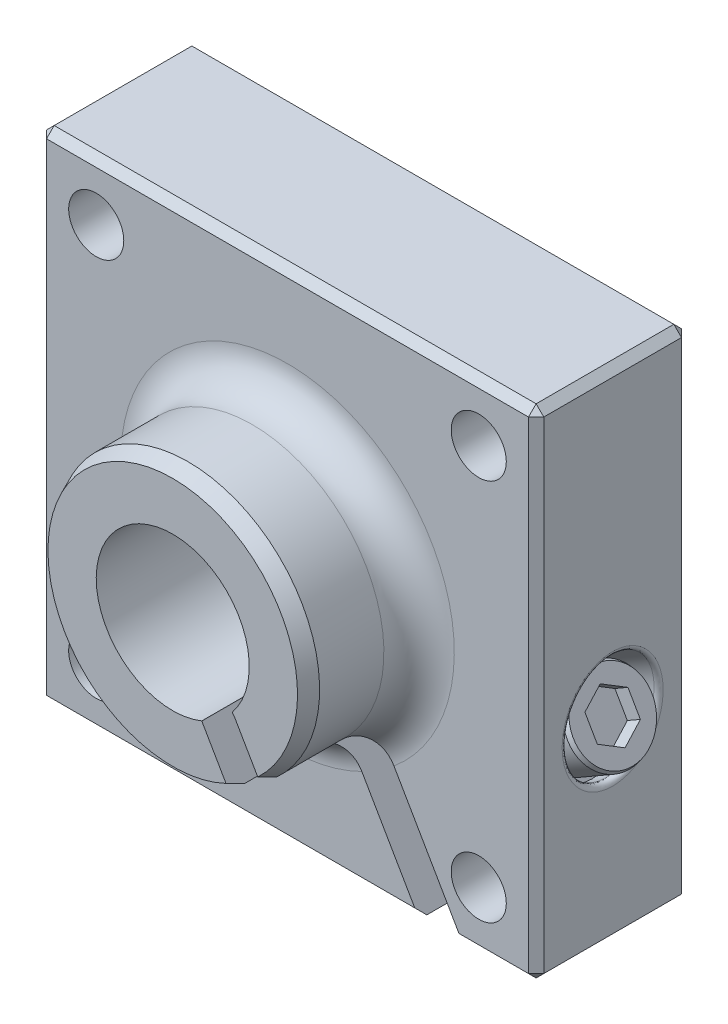
from build123d import *

# Parameters (mm, degrees)
SKETCH4_W               = 41.275
SKETCH4_H               = 41.275
SKETCH4_R               = 2.286
SKETCH4_R_2             = 6.35
BOSS_EXTRUDE1_DEPTH     = 12.7
SKETCH6_R               = 10.922
SKETCH6_R_2             = 6.35
BOSS_EXTRUDE2_DEPTH     = 9.525
CUT_EXTRUDE1_DEPTH      = 23.225
CHAMFER1_SIZE           = 1.27
CHAMFER1_SIZE2          = 0.56544043
CHAMFER3_SIZE           = 0.635
SKETCH18_R              = 2.1463
CUT_EXTRUDE2_DEPTH      = 18.847032
CUT_EXTRUDE2_DEPTH_BACK = 2.54
SKETCH19_R              = 3.81
CUT_EXTRUDE3_DEPTH      = 4.1656
CUT_EXTRUDE3_DEPTH_BACK = 13.484099492
CUT_EXTRUDE4_DEPTH      = 1.24968
CHAMFER4_SIZE           = 0.381
CHAMFER4_SIZE2          = 0.169632129
FILLET1_R               = 0.381
FILLET2_R               = 2.921


with BuildPart() as part:
    # Sketch4 → Boss-Extrude1 (new body)
    with BuildSketch(Plane.XY):
        Rectangle(SKETCH4_W, SKETCH4_H)
        with Locations((-15.875, -15.875)):
            Circle(SKETCH4_R, mode=Mode.SUBTRACT)
        with Locations((15.875, -15.875)):
            Circle(SKETCH4_R, mode=Mode.SUBTRACT)
        with Locations((15.875, 15.875)):
            Circle(SKETCH4_R, mode=Mode.SUBTRACT)
        with Locations((-15.875, 15.875)):
            Circle(SKETCH4_R, mode=Mode.SUBTRACT)
        Circle(SKETCH4_R_2, mode=Mode.SUBTRACT)
    extrude(amount=-BOSS_EXTRUDE1_DEPTH)

    # Sketch6 → Boss-Extrude2 (add)
    with BuildSketch(Plane.XY):
        Circle(SKETCH6_R)
        Circle(SKETCH6_R_2, mode=Mode.SUBTRACT)
    extrude(amount=BOSS_EXTRUDE2_DEPTH)

    # Sketch8 → Cut-Extrude1 (cut, through all)
    with BuildSketch(Plane.XY.offset(9.525)):
        with BuildLine():
            Line((11.388684671, -21.43125), (2.415183293, -5.88868969))
            ThreePointArc((2.415183293, -5.88868969), (2.996248621, -3.720124362), (5.16481395, -4.30118969))
            Line((5.16481395, -4.30118969), (14.138315329, -19.84375))
            ThreePointArc((14.138315329, -19.84375), (13.55725, -22.012315329), (11.388684671, -21.43125))
        make_face()
    extrude(amount=-CUT_EXTRUDE1_DEPTH, mode=Mode.SUBTRACT)

    # Chamfer1
    chamfer1_edges = [part.edges().sort_by_distance(p)[0] for p in [
        (-6.09154739, 9.065491404, 9.525),
    ]]
    chamfer1_side = [part.faces().sort_by_distance(p)[0] for p in [
        (-6.09154739, 9.065491404, 4.7625),
    ]]
    chamfer(chamfer1_edges, length=CHAMFER1_SIZE, length2=CHAMFER1_SIZE2, reference=chamfer1_side[0])

    # Chamfer3
    chamfer3_edges = [part.edges().sort_by_distance(p)[0] for p in [
        (0, 20.6375, -12.7),
        (-20.6375, 0, -12.7),
        (-4.853543552, -20.6375, -12.7),
        (-20.6375, 0, 0),
        (17.49425, -20.6375, -12.7),
        (0, 20.6375, 0),
        (17.49425, -20.6375, 0),
        (20.6375, 0, 0),
        (-4.853543552, -20.6375, 0),
        (20.6375, 0, -12.7),
        (-20.6375, -20.6375, -6.35),
        (-20.6375, 20.6375, -6.35),
        (20.6375, 20.6375, -6.35),
        (20.6375, -20.6375, -6.35),
    ]]
    chamfer(chamfer3_edges, length=CHAMFER3_SIZE)

    # Sketch18 → Cut-Extrude2 (cut, two sides)
    with BuildSketch(Plane(origin=(13.602877332, 7.853624889, 0), x_dir=(0, 0, -1), z_dir=(-0.866025404, -0.5, 0))) as cut_extrude2_sk:
        with Locations((6.35, 14.069245336)):
            Circle(SKETCH18_R)
    extrude(amount=CUT_EXTRUDE2_DEPTH, mode=Mode.SUBTRACT)
    extrude(cut_extrude2_sk.sketch, amount=-CUT_EXTRUDE2_DEPTH_BACK, mode=Mode.SUBTRACT)

    # Sketch19 → Cut-Extrude3 (cut, two sides)
    with BuildSketch(Plane(origin=(13.602877332, 7.853624889, 0), x_dir=(0, 0, -1), z_dir=(-0.866025404, -0.5, 0))) as cut_extrude3_sk:
        with Locations((6.35, 14.069245336)):
            Circle(SKETCH19_R)
    extrude(amount=CUT_EXTRUDE3_DEPTH, mode=Mode.SUBTRACT)
    extrude(cut_extrude3_sk.sketch, amount=-CUT_EXTRUDE3_DEPTH_BACK, mode=Mode.SUBTRACT)

    # Sketch21 → Revolve2 (revolve)
    with BuildSketch(Plane(origin=(7.034622668, -12.184323873, 0), x_dir=(-0.866025404, -0.5, 0), z_dir=(0.5, -0.866025404, 0))):
        Polygon((-15.707249779, 6.35), (7.878464507, 6.35), (7.878464507, 8.4328), (-11.922649779, 8.4328), (-11.922649779, 9.779), (-15.707249779, 9.779), align=None)
    revolve(axis=Axis((20.6375, -4.330698984, -6.35), (-0.866025404, -0.5, 0)))

    # Sketch22 → Cut-Extrude4 (cut)
    with BuildSketch(Plane(origin=(13.602877332, 7.853624889, 0), x_dir=(0, 0, -1), z_dir=(0.866025404, 0.5, 0))):
        Polygon((6.35, -16.131468329), (8.1359375, -15.100356833), (8.1359375, -13.03813384), (6.35, -12.007022344), (4.5640625, -13.03813384), (4.5640625, -15.100356833), align=None)
    extrude(amount=-CUT_EXTRUDE4_DEPTH, mode=Mode.SUBTRACT)

    # Chamfer4
    chamfer4_edges = [part.edges().sort_by_distance(p)[0] for p in [
        (20.6375, -4.330698984, -2.921),
    ]]
    chamfer4_side = [part.faces().sort_by_distance(p)[0] for p in [
        (18.998720128, -5.276848984, -2.921),
    ]]
    chamfer(chamfer4_edges, length=CHAMFER4_SIZE, length2=CHAMFER4_SIZE2, reference=chamfer4_side[0])

    # Fillet1
    fillet1_edges = [part.edges().sort_by_distance(p)[0] for p in [
        (20.6375, -8.730108035, -6.35000004),
        (20.6375, 0.068710067, -6.34999996),
    ]]
    fillet(fillet1_edges, radius=FILLET1_R)

    # Fillet2
    fillet2_edges = [part.edges().sort_by_distance(p)[0] for p in [
        (-6.09154739, 9.065491404, 0),
    ]]
    fillet(fillet2_edges, radius=FILLET2_R)


solid = part.part
